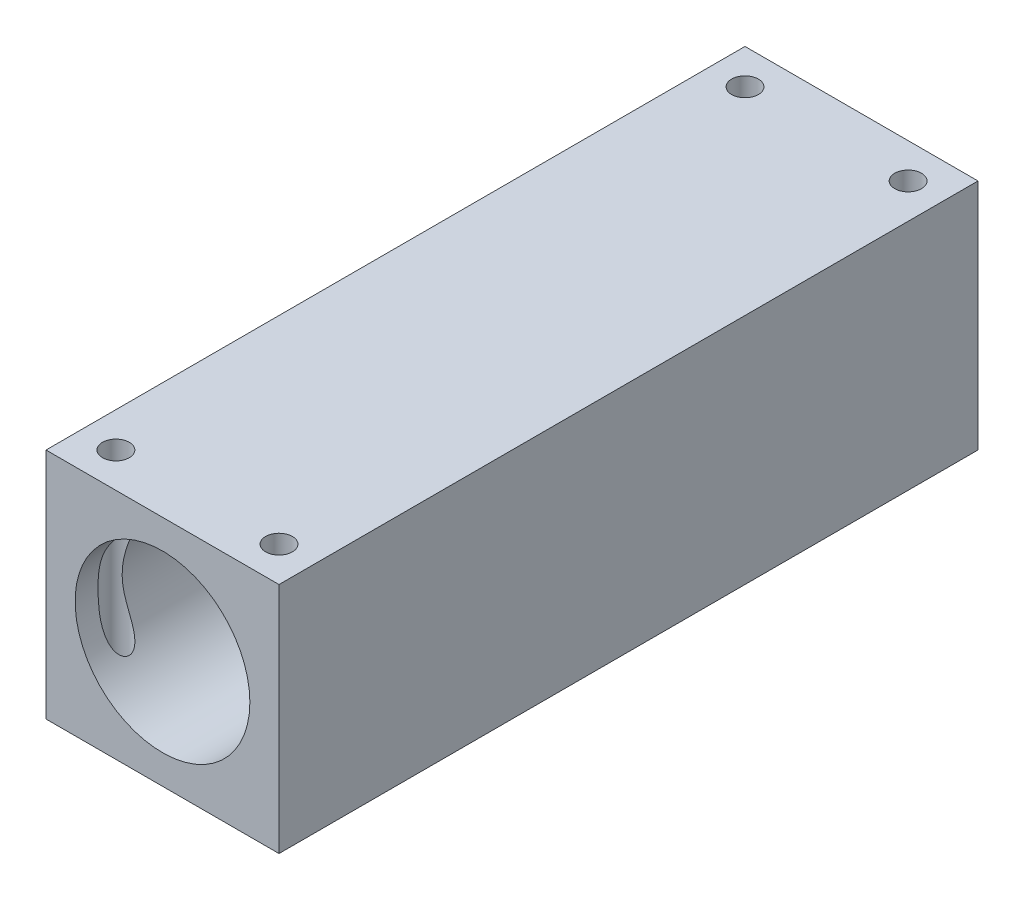
from build123d import *

# Parameters (mm, degrees)
SKETCH1_W           = 20
SKETCH1_H           = 20
SKETCH1_R           = 7.5
BOSS_EXTRUDE1_DEPTH = 60
SKETCH2_R           = 1.15
CUT_EXTRUDE1_DEPTH  = 21


with BuildPart() as part:
    # Sketch1 → Boss-Extrude1 (new body)
    with BuildSketch(Plane.XY):
        with Locations((10, 10)):
            Rectangle(SKETCH1_W, SKETCH1_H)
        with Locations((10, 10)):
            Circle(SKETCH1_R, mode=Mode.SUBTRACT)
    extrude(amount=BOSS_EXTRUDE1_DEPTH)

    # Sketch2 → Cut-Extrude1 (cut, through all)
    with BuildSketch(Plane(origin=(0, 20, 0), x_dir=(1, 0, 0), z_dir=(0, 1, 0))):
        with Locations((3, -57)):
            Circle(SKETCH2_R)
        with Locations((17, -57)):
            Circle(SKETCH2_R)
        with Locations((3, -3)):
            Circle(SKETCH2_R)
        with Locations((17, -3)):
            Circle(SKETCH2_R)
    extrude(amount=-CUT_EXTRUDE1_DEPTH, mode=Mode.SUBTRACT)


solid = part.part
